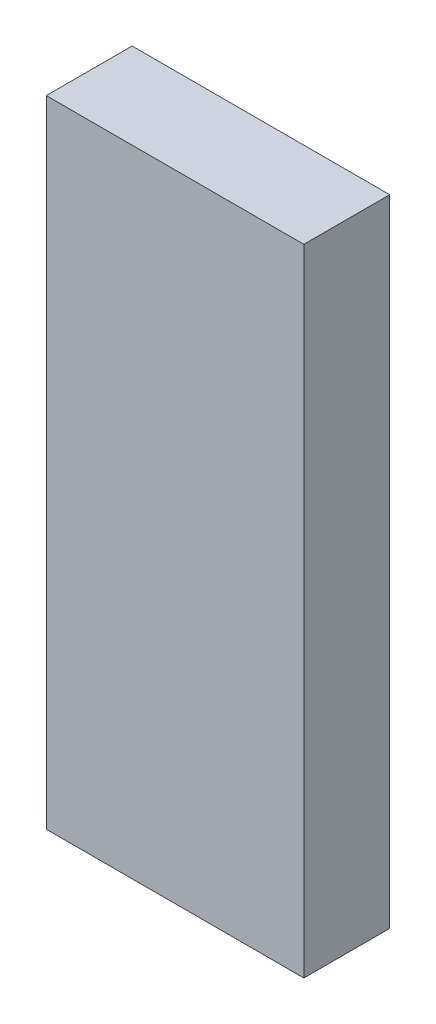
from build123d import *

# Parameters (mm, degrees)
SKETCH25_W          = 38.1
SKETCH25_H          = 12.7
BOSS_EXTRUDE1_DEPTH = 46.99


with BuildPart() as part:
    # Sketch25 → Boss-Extrude1 (new body, symmetric)
    with BuildSketch(Plane(origin=(0, 0, 0), x_dir=(1, 0, 0), z_dir=(0, 1, 0))):
        Rectangle(SKETCH25_W, SKETCH25_H)
    extrude(amount=BOSS_EXTRUDE1_DEPTH, both=True)


solid = part.part
